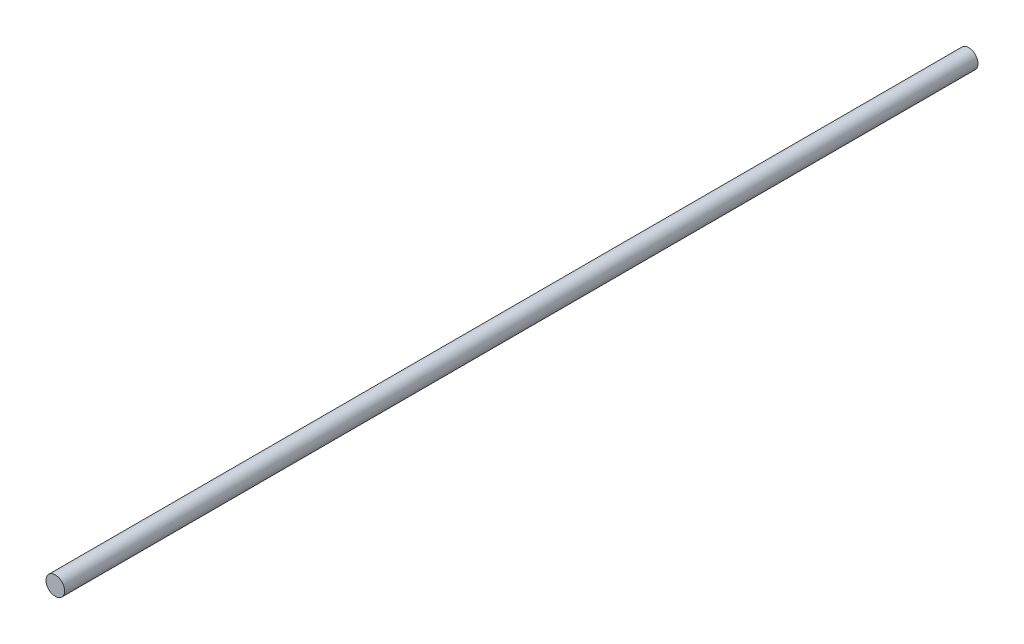
from build123d import *

# Parameters (mm, degrees)
SKETCH1_R           = 10
BOSS_EXTRUDE1_DEPTH = 980


with BuildPart() as part:
    # Sketch1 → Boss-Extrude1 (new body)
    with BuildSketch(Plane.XY):
        Circle(SKETCH1_R)
    extrude(amount=BOSS_EXTRUDE1_DEPTH)


solid = part.part
